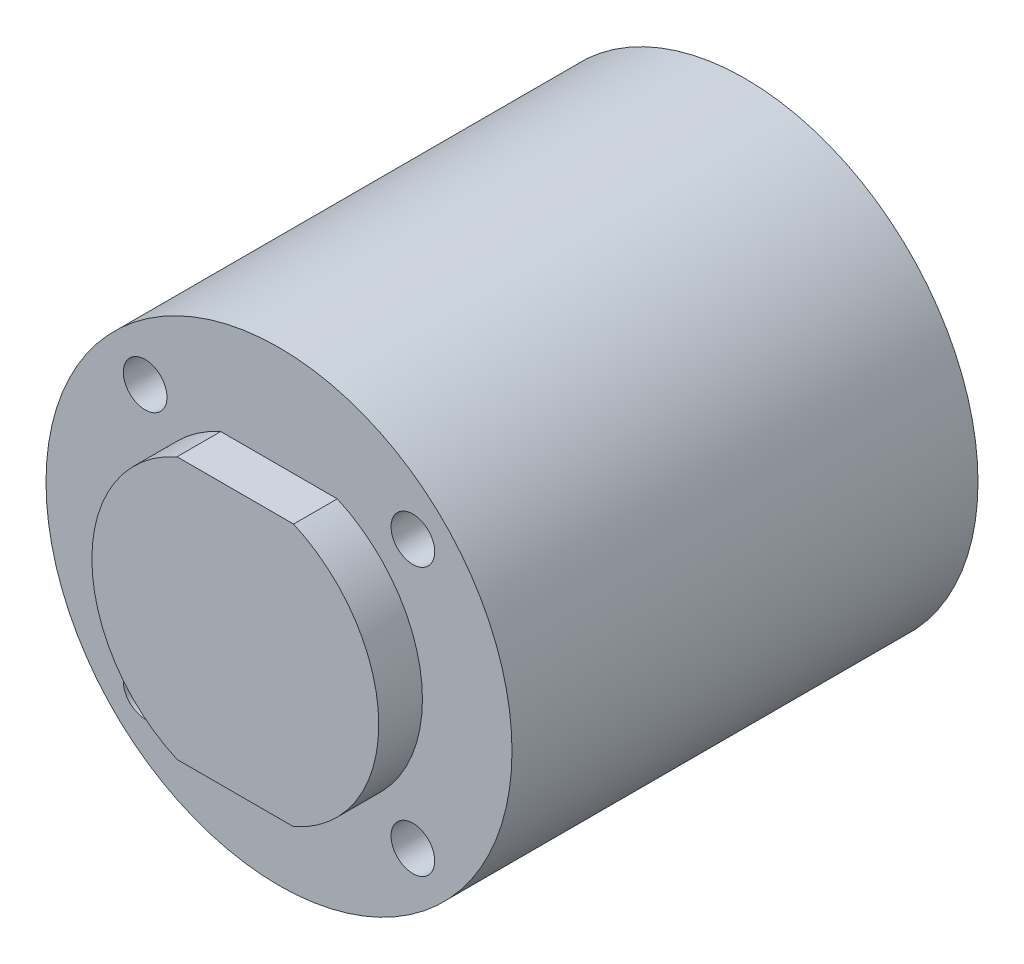
from build123d import *

# Parameters (mm, degrees)
BOSS_EXTRUDE1_DEPTH = 3
SKETCH2_R           = 16
BOSS_EXTRUDE2_DEPTH = 32
SKETCH6_R           = 1.5
CUT_EXTRUDE1_DEPTH  = 10


with BuildPart() as part:
    # Sketch1 → Boss-Extrude1 (new body)
    with BuildSketch(Plane.XY):
        with BuildLine():
            Line((-4.002811512, 9), (4.002811512, 9))
            ThreePointArc((4.002811512, 9), (9.85, 0), (4.002811512, -9))
            Line((4.002811512, -9), (-4.002811512, -9))
            ThreePointArc((-4.002811512, -9), (-9.85, 0), (-4.002811512, 9))
        make_face()
    extrude(amount=BOSS_EXTRUDE1_DEPTH)

    # Sketch2 → Boss-Extrude2 (add)
    with BuildSketch(Plane(origin=(0, 0, 0), x_dir=(-1, 0, 0), z_dir=(0, 0, -1))):
        Circle(SKETCH2_R)
    extrude(amount=BOSS_EXTRUDE2_DEPTH)

    # Sketch6 → Cut-Extrude1 (cut)
    with BuildSketch(Plane.XY):
        with Locations((-9.192388155, 9.192388155)):
            Circle(SKETCH6_R)
        with Locations((9.192388155, 9.192388155)):
            Circle(SKETCH6_R)
        with Locations((9.192388155, -9.192388155)):
            Circle(SKETCH6_R)
        with Locations((-9.192388155, -9.192388155)):
            Circle(SKETCH6_R)
    extrude(amount=-CUT_EXTRUDE1_DEPTH, mode=Mode.SUBTRACT)


solid = part.part
